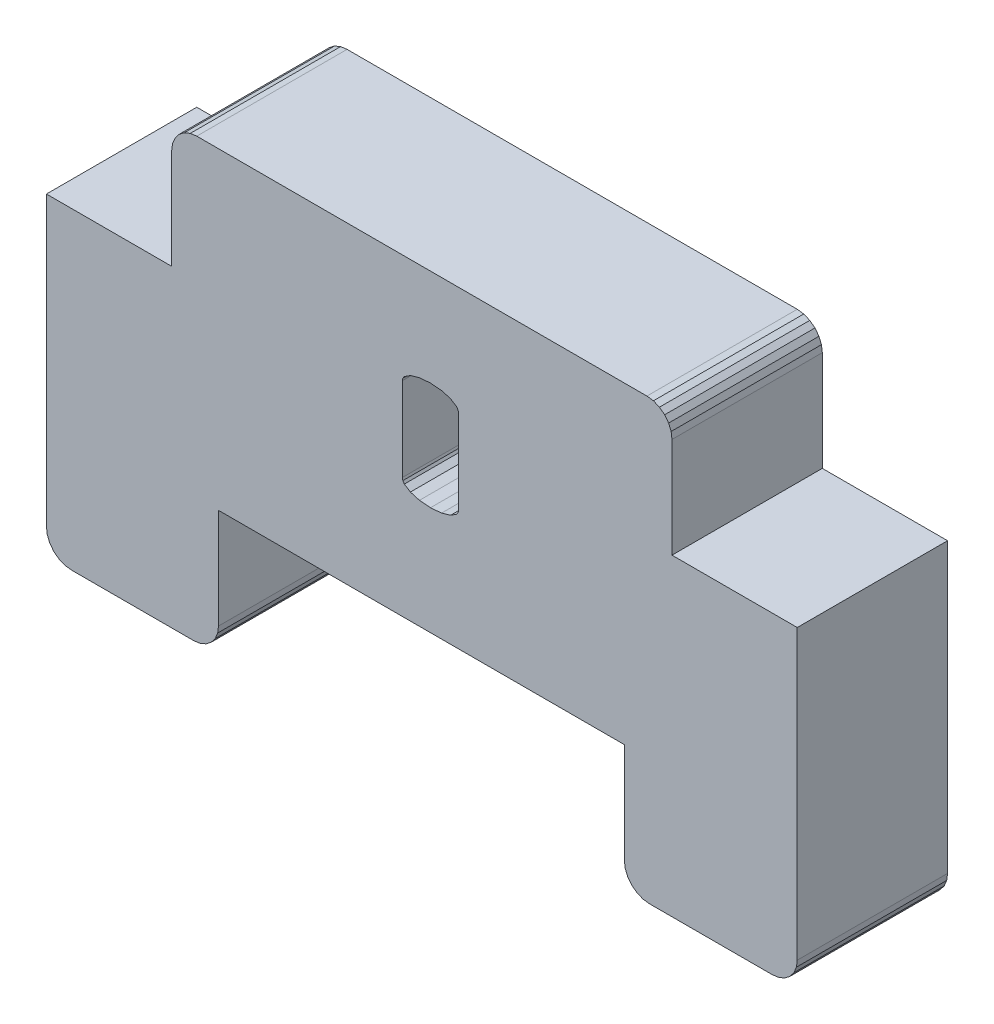
from build123d import *

# Parameters (mm, degrees)
BOSS_EXTRUDE1_DEPTH = 6


with BuildPart() as part:
    # Sketch1 → Boss-Extrude1 (new body)
    with BuildSketch(Plane.XY):
        Polygon((-438.998237574, -234.702156689), (-439.032311747, -234.443337643), (-439.13221217, -234.202156689), (-439.291130792, -233.995049907), (-439.498237574, -233.836131285), (-439.739418528, -233.736230862), (-439.998237574, -233.702156689), (-457.966696735, -233.702156689), (-458.22551578, -233.736230862), (-458.466696735, -233.836131285), (-458.673803517, -233.995049907), (-458.832722139, -234.202156689), (-458.932622562, -234.443337643), (-458.966696735, -234.702156689), (-458.966696735, -238.702156689), (-463.966696735, -238.702156689), (-463.966696735, -250.202156689), (-463.932622562, -250.460975734), (-463.832722139, -250.702156689), (-463.673803517, -250.90926347), (-463.466696735, -251.068182092), (-463.22551578, -251.168082515), (-462.966696735, -251.202156689), (-458.098232577, -251.202156689), (-457.839413532, -251.168082515), (-457.598232577, -251.068182092), (-457.391125796, -250.90926347), (-457.232207174, -250.702156689), (-457.132306751, -250.460975734), (-457.098232577, -250.202156689), (-457.098232577, -246.202156689), (-440.898237574, -246.202156689), (-440.898237574, -250.202156689), (-440.8641634, -250.460975734), (-440.764262977, -250.702156689), (-440.605344355, -250.90926347), (-440.398237574, -251.068182092), (-440.157056619, -251.168082515), (-439.898237574, -251.202156689), (-434.998237574, -251.202156689), (-434.739418528, -251.168082515), (-434.498237574, -251.068182092), (-434.291130792, -250.90926347), (-434.13221217, -250.702156689), (-434.032311747, -250.460975734), (-433.998237574, -250.202156689), (-433.998237574, -238.702156689), (-438.998237574, -238.702156689), align=None)
        Polygon((-449.760974662, -241.400517746), (-449.74087772, -241.496727016), (-449.680586895, -241.585516793), (-449.439423595, -241.740837868), (-449.078059742, -241.846199434), (-448.637070317, -241.881319956), (-448.196080893, -241.846199434), (-447.83471704, -241.740837868), (-447.59355374, -241.585516793), (-447.533262915, -241.496727016), (-447.513165973, -241.400517746), (-447.513165973, -238.05381424), (-447.533262915, -237.957624322), (-447.59355374, -237.868844966), (-447.83471704, -237.713517936), (-448.196080893, -237.608138506), (-448.637070317, -237.573012029), (-449.078059742, -237.608138506), (-449.439423595, -237.713517936), (-449.680586895, -237.868844966), (-449.74087772, -237.957624322), (-449.760974662, -238.05381424), align=None, mode=Mode.SUBTRACT)
    extrude(amount=BOSS_EXTRUDE1_DEPTH)


solid = part.part
